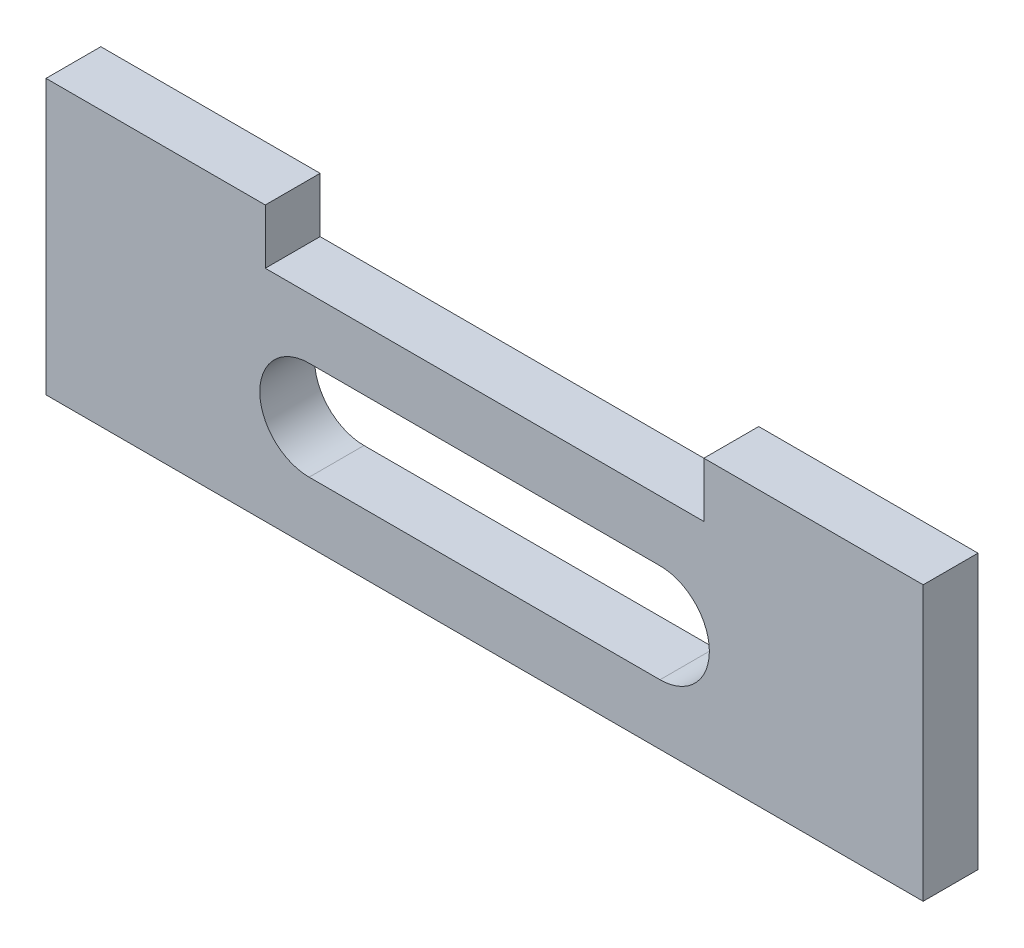
from build123d import *

# Parameters (mm, degrees)
SKETCH1_W       = 50.8
SKETCH1_H       = 12.7
EXTRUDE1_DEPTH  = 3.175
EXTRUDE2_DEPTH  = 4.175
SKETCH3_W       = 12.7
SKETCH3_H       = 3.175
EXTRUDE3_DEPTH  = 3.175
LPATTERN1_COUNT = 2
LPATTERN1_PITCH = 38.1


with BuildPart() as part:
    # Sketch1 → Extrude1 (new body)
    with BuildSketch(Plane.XY):
        with Locations((25.4, 6.35)):
            Rectangle(SKETCH1_W, SKETCH1_H)
    extrude(amount=EXTRUDE1_DEPTH)

    # Sketch2 → Extrude2 (cut, through all)
    with BuildSketch(Plane.XY.offset(3.175)):
        with BuildLine():
            Line((15.24, 9.2075), (35.56, 9.2075))
            ThreePointArc((35.56, 9.2075), (38.4175, 6.35), (35.56, 3.4925))
            Line((35.56, 3.4925), (15.24, 3.4925))
            ThreePointArc((15.24, 3.4925), (12.3825, 6.35), (15.24, 9.2075))
        make_face()
    extrude(amount=-EXTRUDE2_DEPTH, mode=Mode.SUBTRACT)

    # Sketch3 → Extrude3 (add)
    with BuildSketch(Plane(origin=(0, 12.7, 0), x_dir=(1, 0, 0), z_dir=(0, 1, 0))):
        with Locations((6.35, -1.5875)):
            Rectangle(SKETCH3_W, SKETCH3_H)
    extrude3 = extrude(amount=EXTRUDE3_DEPTH)

    # LPattern1: Extrude3 ×2
    with Locations(*[(i * LPATTERN1_PITCH, 0, 0) for i in range(1, LPATTERN1_COUNT)]):
        add(extrude3)


solid = part.part
